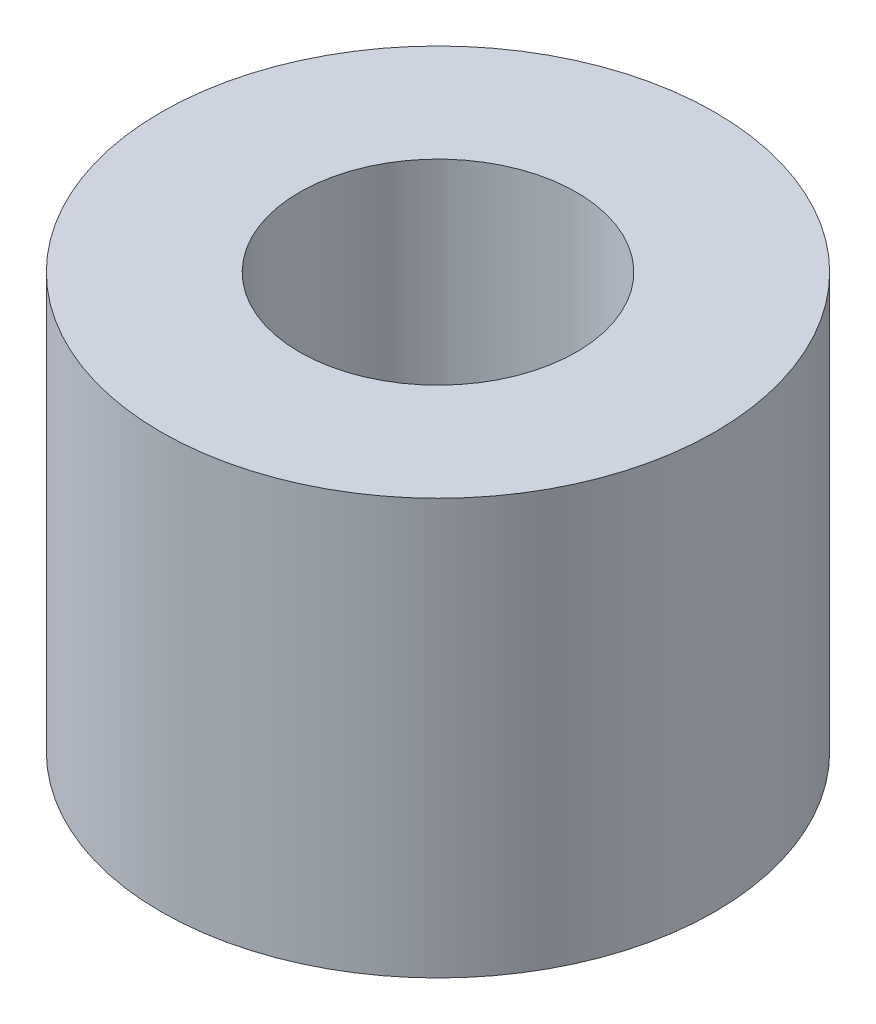
from build123d import *

# Parameters (mm, degrees)
SKETCH1_R           = 6.35
SKETCH1_R_2         = 3.175
BOSS_EXTRUDE1_DEPTH = 4.7625


with BuildPart() as part:
    # Sketch1 → Boss-Extrude1 (new, symmetric)
    with BuildSketch(Plane(origin=(0, 0, 0), x_dir=(1, 0, 0), z_dir=(0, 1, 0))):
        Circle(SKETCH1_R)
        Circle(SKETCH1_R_2, mode=Mode.SUBTRACT)
    extrude(amount=BOSS_EXTRUDE1_DEPTH, both=True)


solid = part.part
